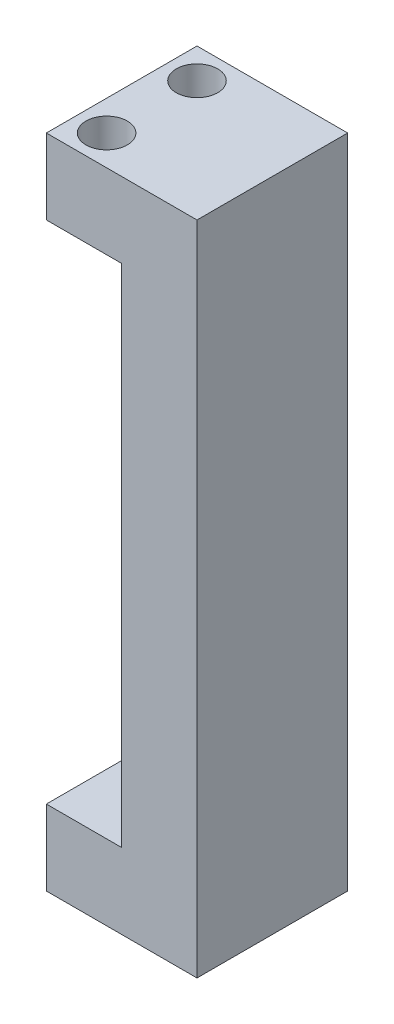
from build123d import *

# Parameters (mm, degrees)
EXTRUDE_1_DEPTH             = 20
HOLE_WIZARD_M4_1_AT_2_COUNT = 2
HOLE_WIZARD_M4_1_AT_2_PITCH = 10
HOLE_WIZARD_M4_1_AT_3_COUNT = 2
HOLE_WIZARD_M4_1_AT_3_PITCH = 10
HOLE_WIZARD_M4_1_AT_4_COUNT = 2
HOLE_WIZARD_M4_1_AT_4_PITCH = 14.142135624
SKETCH_5_W                  = 20
SKETCH_5_H                  = 20
EXTRUDE_2_DEPTH             = 10
SKETCH_6_W                  = 20
SKETCH_6_H                  = 47
CUT_EXTRUDE_2_DEPTH         = 5
SKETCH_7_W                  = 10
SKETCH_7_H                  = 20.15
CUT_EXTRUDE_3_DEPTH         = 21
SKETCH_8_R                  = 2.75
CUT_EXTRUDE_4_DEPTH         = 11


with BuildPart() as part:
    # 草图1 → 凸台-拉伸1 (new body)
    with BuildSketch(Plane.XY):
        Polygon((-20, 30.15), (-15, 30.15), (-15, 77.15), (-20, 77.15), (-20, 87.15), (0, 87.15), (0, 0), (-20, 0), align=None)
    extrude(amount=EXTRUDE_1_DEPTH)

    # 草图3 → M4 螺纹孔1 (revolve, cut)
    with BuildSketch(Plane(origin=(-15, 87.15, 5), x_dir=(0, 0, 1), z_dir=(1, 0, 0))):
        Polygon((0, 0), (0, 6.991420021), (1.65, 6), (1.65, 0), align=None)
    hole_wizard_m4_1 = revolve(axis=Axis((-15, 93.5, 5), (0, -1, 0)), mode=Mode.SUBTRACT)

    # M4 螺纹孔1 at 2: M4 螺纹孔1 ×2
    with Locations(*[(i * HOLE_WIZARD_M4_1_AT_2_PITCH, 0, 0) for i in range(1, HOLE_WIZARD_M4_1_AT_2_COUNT)]):
        add(hole_wizard_m4_1, mode=Mode.SUBTRACT)

    # M4 螺纹孔1 at 3: M4 螺纹孔1 ×2
    with Locations(*[(0, 0, i * HOLE_WIZARD_M4_1_AT_3_PITCH) for i in range(1, HOLE_WIZARD_M4_1_AT_3_COUNT)]):
        add(hole_wizard_m4_1, mode=Mode.SUBTRACT)

    # M4 螺纹孔1 at 4: M4 螺纹孔1 ×2
    with Locations(*[Vector(0.707106781, 0, 0.707106781) * (i * HOLE_WIZARD_M4_1_AT_4_PITCH) for i in range(1, HOLE_WIZARD_M4_1_AT_4_COUNT)]):
        add(hole_wizard_m4_1, mode=Mode.SUBTRACT)

    # 镜向1: M4 螺纹孔1 across plane
    add(hole_wizard_m4_1.mirror(Plane.ZX.offset(43.575)), mode=Mode.SUBTRACT)

    # 镜向1 copy 1 sketch → 镜向1 copy 1 (revolve, cut)
    with BuildSketch(Plane(origin=(-5, 0, 5), x_dir=(0, 0, 1), z_dir=(1, 0, 0))):
        Polygon((0, 0), (0, -6.991420021), (1.65, -6), (1.65, 0), align=None)
    revolve(axis=Axis((-5, -6.35, 5), (0, -1, 0)), mode=Mode.SUBTRACT)

    # 镜向1 copy 2 sketch → 镜向1 copy 2 (revolve, cut)
    with BuildSketch(Plane(origin=(-15, 0, 15), x_dir=(0, 0, 1), z_dir=(1, 0, 0))):
        Polygon((0, 0), (0, -6.991420021), (1.65, -6), (1.65, 0), align=None)
    revolve(axis=Axis((-15, -6.35, 15), (0, -1, 0)), mode=Mode.SUBTRACT)

    # 镜向1 copy 3 sketch → 镜向1 copy 3 (revolve, cut)
    with BuildSketch(Plane(origin=(-5, 0, 15), x_dir=(0, 0, 1), z_dir=(1, 0, 0))):
        Polygon((0, 0), (0, -6.991420021), (1.65, -6), (1.65, 0), align=None)
    revolve(axis=Axis((-5, -6.35, 15), (0, -1, 0)), mode=Mode.SUBTRACT)

    # 草图5 → 凸台-拉伸2 (add)
    with BuildSketch(Plane(origin=(0, 87.15, 0), x_dir=(1, 0, 0), z_dir=(0, 1, 0))):
        with Locations((-10, -10)):
            Rectangle(SKETCH_5_W, SKETCH_5_H)
    extrude(amount=-EXTRUDE_2_DEPTH)

    # 草图6 → 切除-拉伸2 (cut)
    with BuildSketch(Plane.ZY.offset(15)):
        with Locations((10, 53.65)):
            Rectangle(SKETCH_6_W, SKETCH_6_H)
    extrude(amount=-CUT_EXTRUDE_2_DEPTH, mode=Mode.SUBTRACT)

    # 草图7 → 切除-拉伸3 (cut, through all)
    with BuildSketch(Plane.XY.offset(20)):
        with Locations((-15, 20.075)):
            Rectangle(SKETCH_7_W, SKETCH_7_H)
    extrude(amount=-CUT_EXTRUDE_3_DEPTH, mode=Mode.SUBTRACT)

    # 草图8 → 切除-拉伸4 (cut, through all)
    with BuildSketch(Plane.XZ.offset(-77.15)):
        with Locations((-16, 4)):
            Circle(SKETCH_8_R)
        with Locations((-16, 16)):
            Circle(SKETCH_8_R)
    extrude(amount=-CUT_EXTRUDE_4_DEPTH, mode=Mode.SUBTRACT)


solid = part.part
